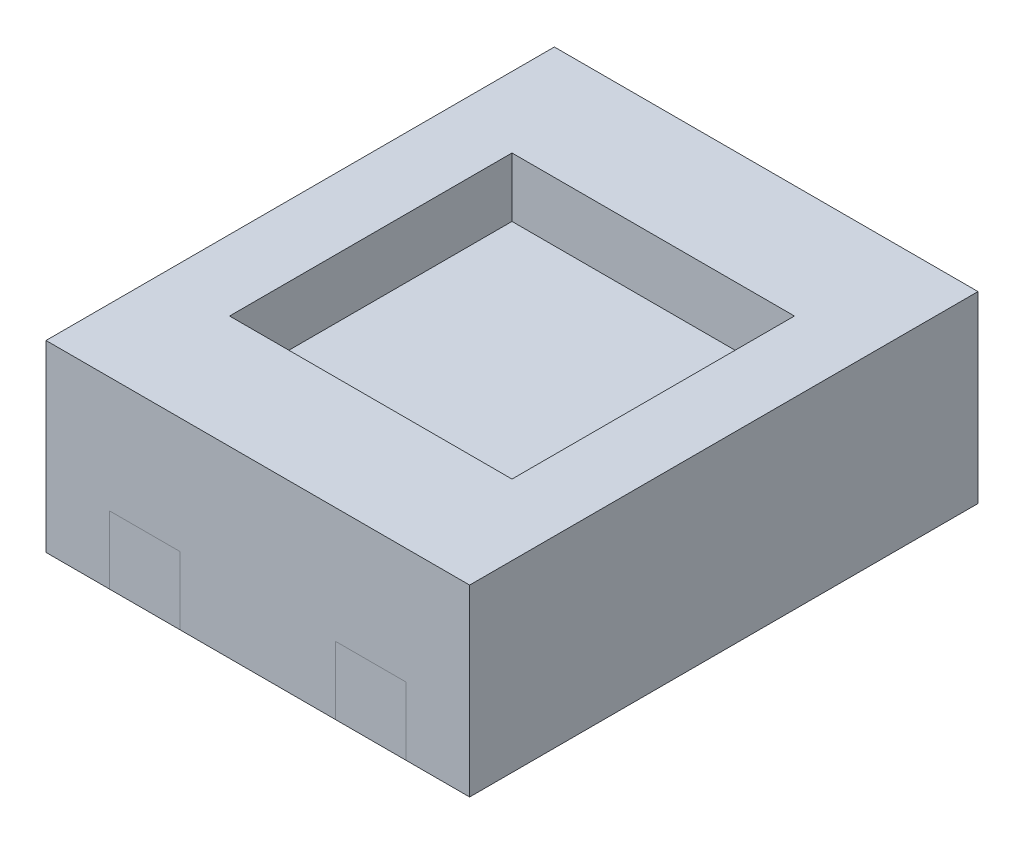
from build123d import *

# Parameters (mm, degrees)
BOSS_EXTRUDE1_DEPTH   = 0.24
SKETCH2_W             = 1
SKETCH2_H             = 1
BOSS_EXTRUDE2_DEPTH   = 0.2
SKETCH3_W             = 1.5
SKETCH3_H             = 1.8
SKETCH3_W_2           = 1
SKETCH3_H_2           = 1
BOSS_EXTRUDE3_DEPTH   = 0.2
SKETCH4_W             = 1.5
SKETCH4_H             = 1.8
BOSS_EXTRUDE4_DEPTH   = 0.21
BOSS_EXTRUDE5_DEPTH   = 0.24
BOSS_EXTRUDE5_2_DEPTH = 0.24
BOSS_EXTRUDE5_3_DEPTH = 0.24
BOSS_EXTRUDE5_4_DEPTH = 0.24
SKETCH6_W             = 1
SKETCH6_H             = 1
CUT_EXTRUDE4_DEPTH    = 0.21


with BuildPart() as part:
    # Sketch1 → Boss-Extrude1 (new body)
    with BuildSketch(Plane(origin=(0, 0, 0), x_dir=(1, 0, 0), z_dir=(0, 1, 0))):
        with BuildLine():
            Line((0.75, 0.9), (0.525, 0.9))
            Line((0.525, 0.9), (0.525, 0.52))
            ThreePointArc((0.525, 0.52), (0.489852814, 0.435147186), (0.405, 0.4))
            Line((0.405, 0.4), (0.395, 0.4))
            ThreePointArc((0.395, 0.4), (0.310147186, 0.435147186), (0.275, 0.52))
            Line((0.275, 0.52), (0.275, 0.9))
            Line((0.275, 0.9), (-0.275, 0.9))
            Line((-0.275, 0.9), (-0.275, 0.52))
            ThreePointArc((-0.275, 0.52), (-0.310147186, 0.435147186), (-0.395, 0.4))
            Line((-0.395, 0.4), (-0.405, 0.4))
            ThreePointArc((-0.405, 0.4), (-0.489852814, 0.435147186), (-0.525, 0.52))
            Line((-0.525, 0.52), (-0.525, 0.9))
            Line((-0.525, 0.9), (-0.75, 0.9))
            Line((-0.75, 0.9), (-0.75, -0.9))
            Line((-0.75, -0.9), (-0.525, -0.9))
            Line((-0.525, -0.9), (-0.525, -0.52))
            ThreePointArc((-0.525, -0.52), (-0.489852814, -0.435147186), (-0.405, -0.4))
            Line((-0.405, -0.4), (-0.395, -0.4))
            ThreePointArc((-0.395, -0.4), (-0.310147186, -0.435147186), (-0.275, -0.52))
            Line((-0.275, -0.52), (-0.275, -0.9))
            Line((-0.275, -0.9), (0.275, -0.9))
            Line((0.275, -0.9), (0.275, -0.52))
            ThreePointArc((0.275, -0.52), (0.310147186, -0.435147186), (0.395, -0.4))
            Line((0.395, -0.4), (0.405, -0.4))
            ThreePointArc((0.405, -0.4), (0.489852814, -0.435147186), (0.525, -0.52))
            Line((0.525, -0.52), (0.525, -0.9))
            Line((0.525, -0.9), (0.75, -0.9))
            Line((0.75, -0.9), (0.75, 0.9))
        make_face()
    extrude(amount=BOSS_EXTRUDE1_DEPTH)

    # Sketch3 → Boss-Extrude3 (add)
    with BuildSketch(Plane(origin=(0, 0.24, 0), x_dir=(1, 0, 0), z_dir=(0, 1, 0))):
        Rectangle(SKETCH3_W, SKETCH3_H)
        Rectangle(SKETCH3_W_2, SKETCH3_H_2, mode=Mode.SUBTRACT)
    extrude(amount=BOSS_EXTRUDE3_DEPTH)

    # Sketch4 → Boss-Extrude4 (add)
    with BuildSketch(Plane(origin=(0, 0.44, 0), x_dir=(1, 0, 0), z_dir=(0, 1, 0))):
        Rectangle(SKETCH4_W, SKETCH4_H)
    extrude(amount=BOSS_EXTRUDE4_DEPTH)

    # Sketch6 → Cut-Extrude4 (cut)
    with BuildSketch(Plane(origin=(0, 0.65, 0), x_dir=(1, 0, 0), z_dir=(0, 1, 0))):
        Rectangle(SKETCH6_W, SKETCH6_H)
    extrude(amount=-CUT_EXTRUDE4_DEPTH, mode=Mode.SUBTRACT)


with BuildPart() as body_2:
    # Sketch2 → Boss-Extrude2 (new body)
    with BuildSketch(Plane(origin=(0, 0.24, 0), x_dir=(1, 0, 0), z_dir=(0, 1, 0))):
        Rectangle(SKETCH2_W, SKETCH2_H)
    extrude(amount=BOSS_EXTRUDE2_DEPTH)


with BuildPart() as body_3:
    # Sketch5 → Boss-Extrude5 (new body)
    with BuildSketch(Plane.XZ.offset(-0.24)):
        with BuildLine():
            Line((0.525, -0.9), (0.275, -0.9))
            Line((0.275, -0.9), (0.275, -0.52))
            ThreePointArc((0.275, -0.52), (0.310147186, -0.435147186), (0.395, -0.4))
            Line((0.395, -0.4), (0.405, -0.4))
            ThreePointArc((0.405, -0.4), (0.489852814, -0.435147186), (0.525, -0.52))
            Line((0.525, -0.52), (0.525, -0.9))
        make_face()
    extrude(amount=BOSS_EXTRUDE5_DEPTH)


with BuildPart() as body_4:
    # Sketch5 → Boss-Extrude5 2 (new body)
    with BuildSketch(Plane.XZ.offset(-0.24)):
        with BuildLine():
            Line((-0.395, -0.4), (-0.405, -0.4))
            ThreePointArc((-0.405, -0.4), (-0.489852814, -0.435147186), (-0.525, -0.52))
            Line((-0.525, -0.52), (-0.525, -0.9))
            Line((-0.525, -0.9), (-0.275, -0.9))
            Line((-0.275, -0.9), (-0.275, -0.52))
            ThreePointArc((-0.275, -0.52), (-0.310147186, -0.435147186), (-0.395, -0.4))
        make_face()
    extrude(amount=BOSS_EXTRUDE5_2_DEPTH)


with BuildPart() as body_5:
    # Sketch5 → Boss-Extrude5 3 (new body)
    with BuildSketch(Plane.XZ.offset(-0.24)):
        with BuildLine():
            Line((-0.525, 0.9), (-0.275, 0.9))
            Line((-0.275, 0.9), (-0.275, 0.52))
            ThreePointArc((-0.275, 0.52), (-0.310147186, 0.435147186), (-0.395, 0.4))
            Line((-0.395, 0.4), (-0.405, 0.4))
            ThreePointArc((-0.405, 0.4), (-0.489852814, 0.435147186), (-0.525, 0.52))
            Line((-0.525, 0.52), (-0.525, 0.9))
        make_face()
    extrude(amount=BOSS_EXTRUDE5_3_DEPTH)


with BuildPart() as body_6:
    # Sketch5 → Boss-Extrude5 4 (new body)
    with BuildSketch(Plane.XZ.offset(-0.24)):
        with BuildLine():
            Line((0.275, 0.9), (0.525, 0.9))
            Line((0.525, 0.9), (0.525, 0.52))
            ThreePointArc((0.525, 0.52), (0.489852814, 0.435147186), (0.405, 0.4))
            Line((0.405, 0.4), (0.395, 0.4))
            ThreePointArc((0.395, 0.4), (0.310147186, 0.435147186), (0.275, 0.52))
            Line((0.275, 0.52), (0.275, 0.9))
        make_face()
    extrude(amount=BOSS_EXTRUDE5_4_DEPTH)


solid = Compound([part.part, body_2.part, body_3.part, body_4.part, body_5.part, body_6.part])
